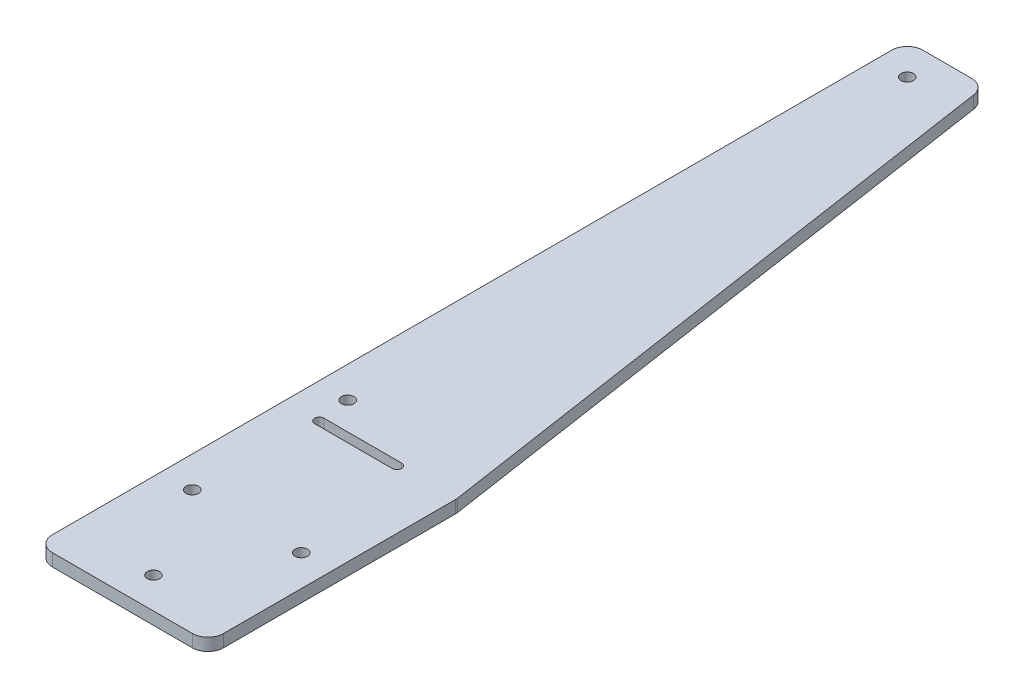
from build123d import *

# Parameters (mm, degrees)
SKETCH1_R           = 1
BOSS_EXTRUDE1_DEPTH = 2


with BuildPart() as part:
    # Sketch1 → Boss-Extrude1 (new body)
    with BuildSketch(Plane(origin=(0, 0, 0), x_dir=(1, 0, 0), z_dir=(0, 1, 0))):
        with BuildLine():
            Line((-50, -63.396226415), (-50, 54.103773585))
            ThreePointArc((-50, 54.103773585), (-49.267766953, 55.871540538), (-47.5, 56.603773585))
            Line((-47.5, 56.603773585), (-39.652542771, 56.603773585))
            ThreePointArc((-39.652542771, 56.603773585), (-38.021337196, 55.998283646), (-37.180274472, 54.475108283))
            Line((-37.180274472, 54.475108283), (-22.507731701, -43.211594583))
            ThreePointArc((-22.507731701, -43.211594583), (-22.486942565, -43.396744894), (-22.48, -43.582929282))
            Line((-22.48, -43.582929282), (-22.48, -63.396226415))
            Line((-22.48, -63.396226415), (-22.48, -78.396226415))
            Line((-22.48, -78.396226415), (-22.48, -80.896226415))
            ThreePointArc((-22.48, -80.896226415), (-23.212233047, -82.663993368), (-24.98, -83.396226415))
            Line((-24.98, -83.396226415), (-47.5, -83.396226415))
            ThreePointArc((-47.5, -83.396226415), (-49.267766953, -82.663993368), (-50, -80.896226415))
            Line((-50, -80.896226415), (-50, -78.396226415))
            Line((-50, -78.396226415), (-50, -63.396226415))
        make_face()
        with Locations((-36.24, -78.396226415)):
            Circle(SKETCH1_R, mode=Mode.SUBTRACT)
        with Locations((-45, -63.396226415)):
            Circle(SKETCH1_R, mode=Mode.SUBTRACT)
        with Locations((-27.48, -63.396226415)):
            Circle(SKETCH1_R, mode=Mode.SUBTRACT)
        with Locations((-45, -38.396226415)):
            Circle(SKETCH1_R, mode=Mode.SUBTRACT)
        with Locations((-45, 51.603773585)):
            Circle(SKETCH1_R, mode=Mode.SUBTRACT)
        with BuildLine():
            Line((-44.38816659, -42.832929282), (-31.88816659, -42.832929282))
            ThreePointArc((-31.88816659, -42.832929282), (-31.13816659, -43.582929282), (-31.88816659, -44.332929282))
            Line((-31.88816659, -44.332929282), (-44.38816659, -44.332929282))
            ThreePointArc((-44.38816659, -44.332929282), (-45.13816659, -43.582929282), (-44.38816659, -42.832929282))
        make_face(mode=Mode.SUBTRACT)
    extrude(amount=BOSS_EXTRUDE1_DEPTH)


solid = part.part
